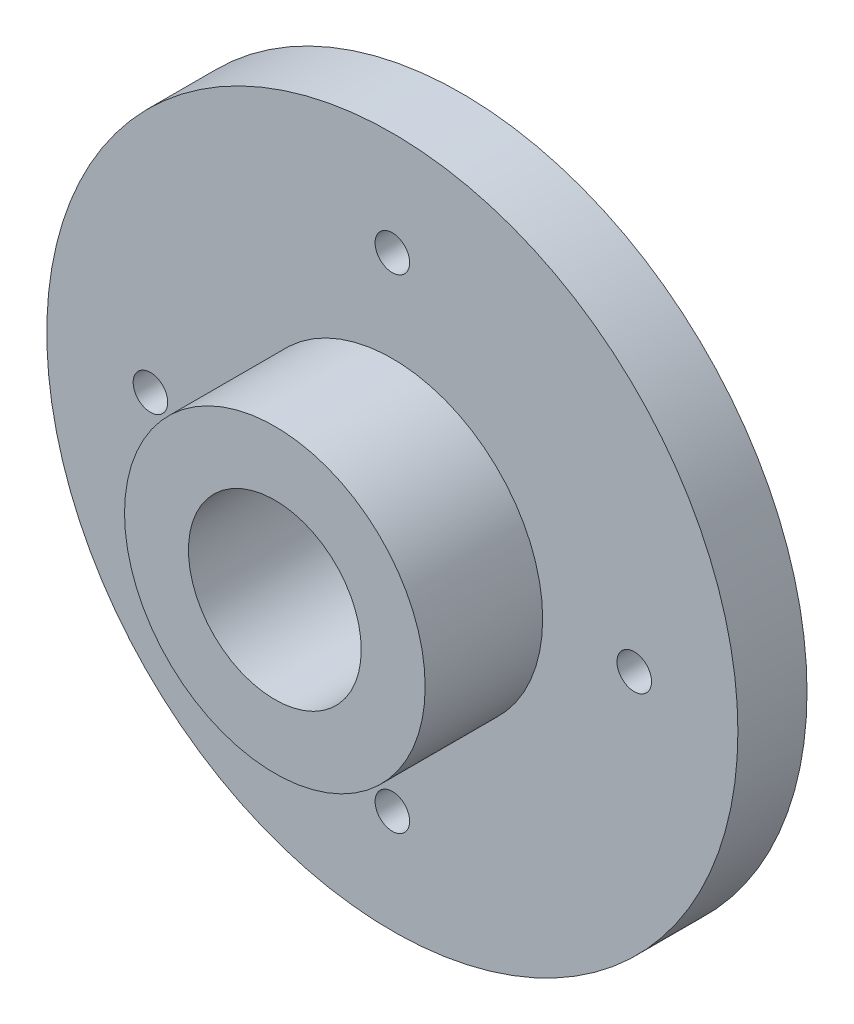
from build123d import *

# Parameters (mm, degrees)
SKETCH_1_R          = 10
EXTRUDE_1_DEPTH     = 2
SKETCH_2_R          = 4.35
EXTRUDE_2_DEPTH     = 3.4
SKETCH_3_R          = 1.5
CUT_EXTRUDE_1_DEPTH = 9.4
SKETCH_4_R          = 0.5
CUT_EXTRUDE_3_DEPTH = 16.4
SKETCH_5_R          = 2.5
CUT_EXTRUDE_4_DEPTH = 4.4


with BuildPart() as part:
    # 草图1 → 凸台-拉伸1 (new body)
    with BuildSketch(Plane.XY):
        Circle(SKETCH_1_R)
    extrude(amount=EXTRUDE_1_DEPTH)

    # 草图2 → 凸台-拉伸2 (add)
    with BuildSketch(Plane.XY.offset(2)):
        Circle(SKETCH_2_R)
    extrude(amount=EXTRUDE_2_DEPTH)

    # 草图3 → 切除-拉伸1 (cut)
    with BuildSketch(Plane.XY):
        Circle(SKETCH_3_R)
    extrude(amount=CUT_EXTRUDE_1_DEPTH, mode=Mode.SUBTRACT)

    # 草图4 → 切除-拉伸3 (cut)
    with BuildSketch(Plane.XY):
        with Locations((0, 7)):
            Circle(SKETCH_4_R)
        with Locations((7, 0)):
            Circle(SKETCH_4_R)
        with Locations((0, -7)):
            Circle(SKETCH_4_R)
        with Locations((-7, 0)):
            Circle(SKETCH_4_R)
    extrude(amount=CUT_EXTRUDE_3_DEPTH, mode=Mode.SUBTRACT)

    # 草图5 → 切除-拉伸4 (cut)
    with BuildSketch(Plane.XY.offset(5.4)):
        Circle(SKETCH_5_R)
    extrude(amount=-CUT_EXTRUDE_4_DEPTH, mode=Mode.SUBTRACT)


solid = part.part
